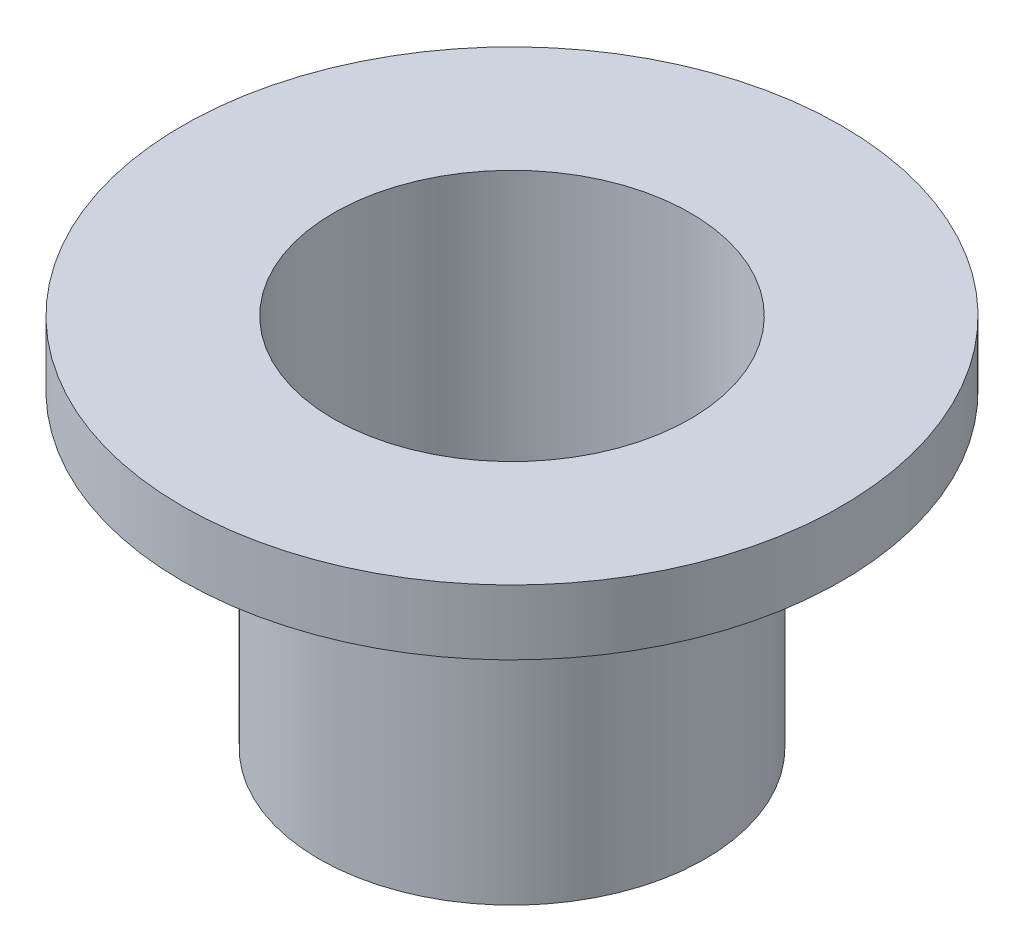
from build123d import *


with BuildPart() as part:
    # Sketch1 → Revolve1 (revolve)
    with BuildSketch(Plane(origin=(0, 0, 0), x_dir=(0, 0, -1), z_dir=(1, 0, 0))):
        Polygon((2.75, 5.7625), (2.75, 0), (2.975, 0), (2.975, 4.7625), (5.08, 4.7625), (5.08, 5.7625), align=None)
    revolve(axis=Axis((0, 12.1046875, 0), (0, -1, 0)))


solid = part.part
